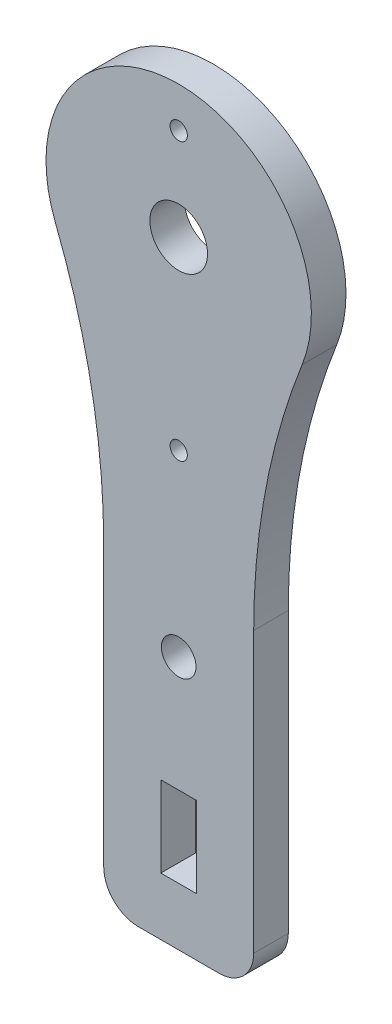
from build123d import *

# Parameters (mm, degrees)
SALIENTE_EXTRUIR1_DEPTH = 3
CROQUIS2_R              = 2.5
CROQUIS2_R_2            = 1.5
CROQUIS2_W              = 3.1
CROQUIS2_H              = 7
CORTAR_EXTRUIR1_DEPTH   = 3
REDONDEO1_R             = 60
REDONDEO2_R             = 3
CROQUIS3_R              = 0.75
CORTAR_EXTRUIR2_DEPTH   = 3


with BuildPart() as part:
    # Croquis1 → Saliente-Extruir1 (new body)
    with BuildSketch(Plane.XY):
        with BuildLine():
            Line((-6.5, -53.5), (6.5, -53.5))
            Line((6.5, -53.5), (6.5, -9.486832981))
            ThreePointArc((6.5, -9.486832981), (0, -11.5), (-6.5, -9.486832981))
            Line((-6.5, -9.486832981), (-6.5, -53.5))
        make_face()
        with BuildLine():
            ThreePointArc((-6.5, -9.486832981), (0, -11.5), (6.5, -9.486832981))
            Line((6.5, -9.486832981), (6.5, 0))
            Line((6.5, 0), (-6.5, 0))
            Line((-6.5, 0), (-6.5, -9.486832981))
        make_face()
        with BuildLine():
            Line((6.5, 0), (6.5, -9.486832981))
            ThreePointArc((6.5, -9.486832981), (10.173494975, -5.361902647), (11.5, 0))
            ThreePointArc((11.5, 0), (-5.361902647, 10.173494975), (-6.5, -9.486832981))
            Line((-6.5, -9.486832981), (-6.5, 0))
            Line((-6.5, 0), (6.5, 0))
        make_face()
    extrude(amount=SALIENTE_EXTRUIR1_DEPTH)

    # Croquis2 → Cortar-Extruir1 (cut)
    with BuildSketch(Plane.XY.offset(3)):
        Circle(CROQUIS2_R)
        with Locations((0, -31.5)):
            Circle(CROQUIS2_R_2)
        with Locations((0, -45)):
            Rectangle(CROQUIS2_W, CROQUIS2_H)
    extrude(amount=-CORTAR_EXTRUIR1_DEPTH, mode=Mode.SUBTRACT)

    # Redondeo1
    redondeo1_edges = [part.edges().sort_by_distance(p)[0] for p in [
        (-6.5, -9.486832981, 1.5),
        (6.5, -9.486832981, 1.5),
    ]]
    fillet(redondeo1_edges, radius=REDONDEO1_R)

    # Redondeo2
    redondeo2_edges = [part.edges().sort_by_distance(p)[0] for p in [
        (6.5, -53.5, 1.5),
        (-6.5, -53.5, 1.5),
    ]]
    fillet(redondeo2_edges, radius=REDONDEO2_R)

    # Croquis3 → Cortar-Extruir2 (cut)
    with BuildSketch(Plane.XY.offset(3)):
        with Locations((0, 8)):
            Circle(CROQUIS3_R)
        with Locations((0, -16)):
            Circle(CROQUIS3_R)
    extrude(amount=-CORTAR_EXTRUIR2_DEPTH, mode=Mode.SUBTRACT)


solid = part.part
